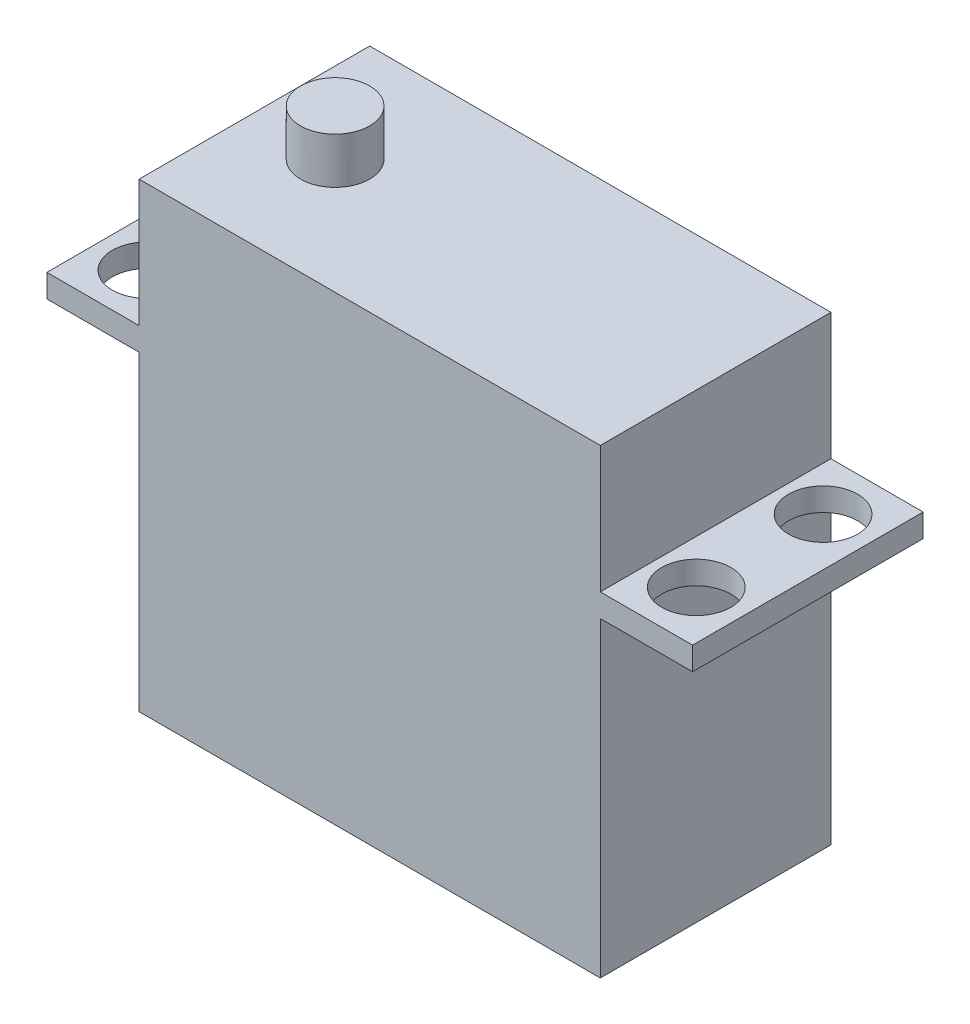
from build123d import *

# Parameters (mm, degrees)
SKETCH1_W           = 40
SKETCH1_H           = 20
BOSS_EXTRUDE1_DEPTH = 40
SKETCH2_R           = 3
BOSS_EXTRUDE2_DEPTH = 4
SKETCH3_W           = 20
SKETCH3_H           = 2
BOSS_EXTRUDE3_DEPTH = 8
SKETCH4_R           = 3
CUT_EXTRUDE1_DEPTH  = 30


with BuildPart() as part:
    # Sketch1 → Boss-Extrude1 (new body)
    with BuildSketch(Plane(origin=(0, 0, 0), x_dir=(1, 0, 0), z_dir=(0, 1, 0))):
        Rectangle(SKETCH1_W, SKETCH1_H)
    extrude(amount=BOSS_EXTRUDE1_DEPTH)

    # Sketch2 → Boss-Extrude2 (add)
    with BuildSketch(Plane(origin=(0, 40, 0), x_dir=(1, 0, 0), z_dir=(0, 1, 0))):
        with Locations((-13, 0)):
            Circle(SKETCH2_R)
    extrude(amount=BOSS_EXTRUDE2_DEPTH)

    # Sketch3 → Boss-Extrude3 (add)
    with BuildSketch(Plane(origin=(20, 0, 0), x_dir=(0, 0, -1), z_dir=(1, 0, 0))):
        with Locations((0, 28)):
            Rectangle(SKETCH3_W, SKETCH3_H)
    boss_extrude3 = extrude(amount=BOSS_EXTRUDE3_DEPTH)

    # Sketch4 → Cut-Extrude1 (cut, through all)
    with BuildSketch(Plane(origin=(0, 29, 0), x_dir=(1, 0, 0), z_dir=(0, 1, 0))):
        with Locations((23.821894681, 5.5)):
            Circle(SKETCH4_R)
        with Locations((23.821894681, -5.5)):
            Circle(SKETCH4_R)
    cut_extrude1 = extrude(amount=-CUT_EXTRUDE1_DEPTH, mode=Mode.SUBTRACT)

    # Mirror2: Boss-Extrude3, Cut-Extrude1 across plane
    add(boss_extrude3.mirror(Plane(origin=(0, 0, 0), x_dir=(0, 0, 1), z_dir=(1, 0, 0))))
    add(cut_extrude1.mirror(Plane(origin=(0, 0, 0), x_dir=(0, 0, 1), z_dir=(1, 0, 0))), mode=Mode.SUBTRACT)


solid = part.part
